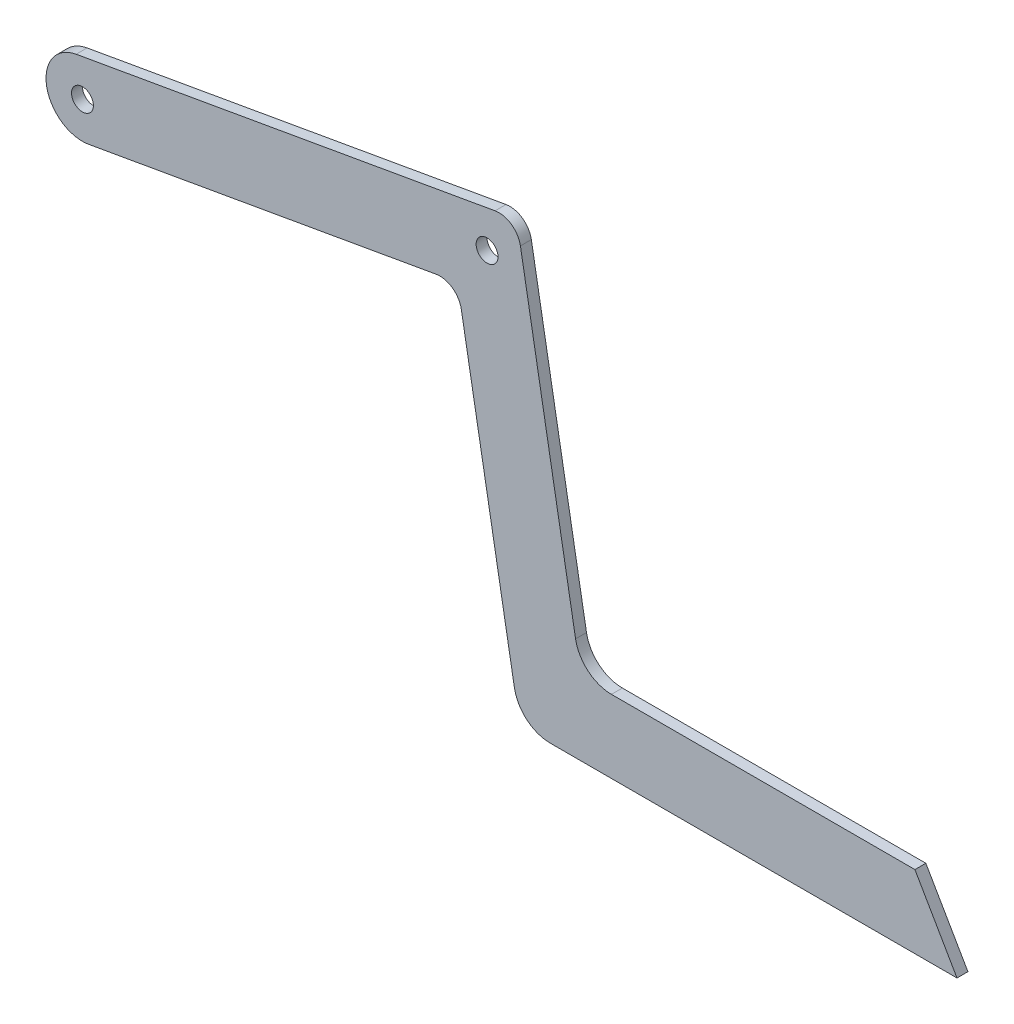
from build123d import *

# Parameters (mm, degrees)
SKETCH1_R           = 1.5
BOSS_EXTRUDE1_DEPTH = 0.75


with BuildPart() as part:
    # Sketch1 → Boss-Extrude1 (new body, symmetric)
    with BuildSketch(Plane.XY):
        with BuildLine():
            Line((4.195498156, 0), (60, 0))
            Line((60, 0), (54.226497308, 10))
            Line((54.226497308, 10), (12.586494468, 10))
            ThreePointArc((12.586494468, 10), (9.372556419, 11.169777784), (7.662455703, 14.131759112))
            Line((7.662455703, 14.131759112), (0.095591809, 57.045576741))
            ThreePointArc((0.095591809, 57.045576741), (-1.138102141, 58.982088341), (-3.379775983, 59.479055467))
            Line((-3.379775983, 59.479055467), (-60.868240888, 49.342288025))
            ThreePointArc((-60.868240888, 49.342288025), (-64.924038765, 43.550008371), (-59.131759112, 39.494210494))
            Line((-59.131759112, 39.494210494), (-11.491371736, 47.89449616))
            ThreePointArc((-11.491371736, 47.89449616), (-9.249697894, 47.397529034), (-8.016003944, 45.461017434))
            Line((-8.016003944, 45.461017434), (-0.728540609, 4.131759112))
            ThreePointArc((-0.728540609, 4.131759112), (0.981560107, 1.169777784), (4.195498156, 0))
        make_face()
        with Locations((-60, 44.41824926)):
            Circle(SKETCH1_R, mode=Mode.SUBTRACT)
        with Locations((-4.4811506, 54.207720347)):
            Circle(SKETCH1_R, mode=Mode.SUBTRACT)
    extrude(amount=BOSS_EXTRUDE1_DEPTH, both=True)


solid = part.part
